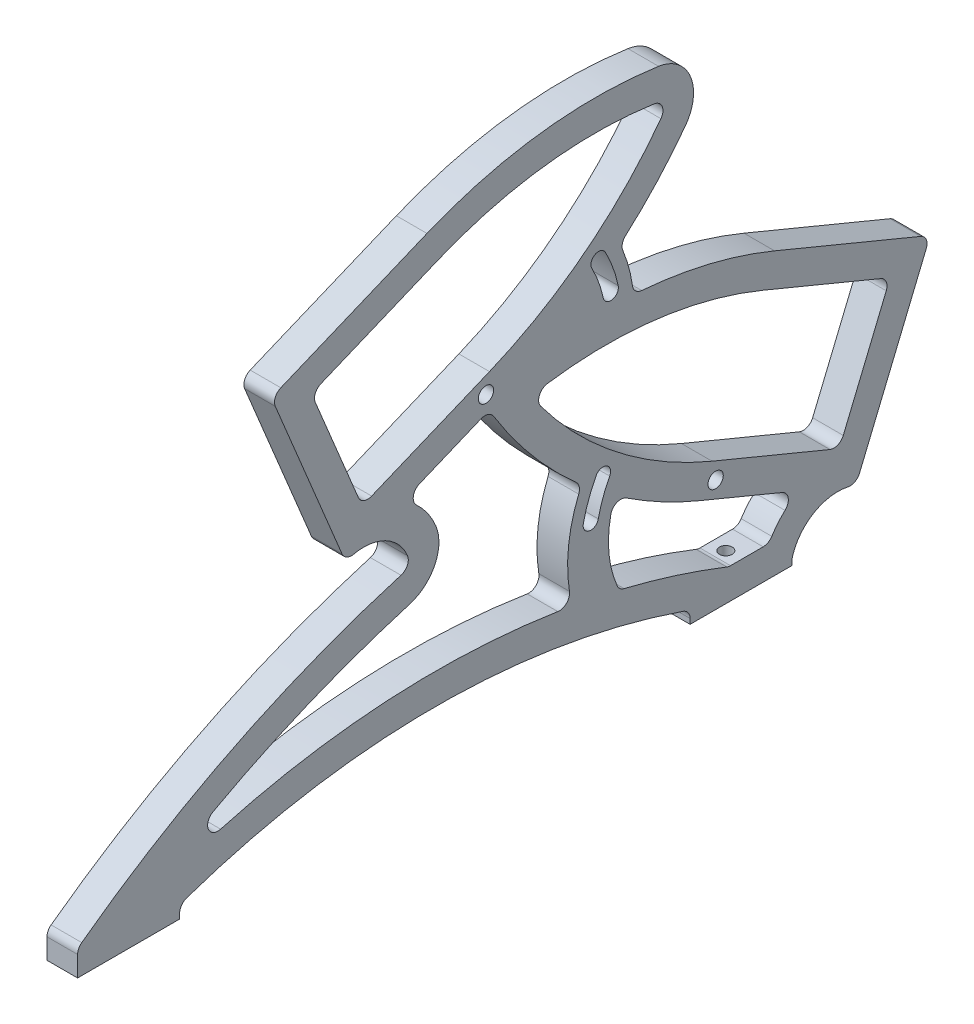
from build123d import *

# Parameters (mm, degrees)
SKETCH1_R                   = 1.5
BOSS_EXTRUDE1_DEPTH         = 6
FILLET1_R                   = 2
TAP_DRILL_FOR_M3_TAP1_D     = 2.5
TAP_DRILL_FOR_M3_TAP1_DEPTH = 10
TAP_DRILL_FOR_M3_TAP1_TIP   = 0.751075774


with BuildPart() as part:
    # Sketch1 → Boss-Extrude1 (new body)
    with BuildSketch(Plane(origin=(0, 0, 0), x_dir=(0, 0, -1), z_dir=(1, 0, 0))):
        with BuildLine():
            Line((0, 0), (0, 5))
            ThreePointArc((0, 5), (30.263904534, 23.654794569), (63.35257649, 36.656527771))
            ThreePointArc((63.35257649, 36.656527771), (64.593543685, 37.712278476), (64.63724154, 39.340989509))
            ThreePointArc((64.63724154, 39.340989509), (59.61305605, 44.365174999), (52.507784789, 44.365174999))
            Line((52.507784789, 44.365174999), (37.965814359, 79.472597235))
            Line((37.965814359, 79.472597235), (68.453838932, 92.101150503))
            ThreePointArc((68.453838932, 92.101150503), (90.758303247, 97.999189725), (113.828291361, 97.771937753))
            ThreePointArc((113.828291361, 97.771937753), (120.071041294, 92.916243967), (119.090244487, 85.068459153))
            ThreePointArc((119.090244487, 85.068459153), (113.049914098, 77.838922298), (106.256946475, 71.311489017))
            ThreePointArc((106.256946475, 71.311489017), (108.007602478, 66.521582509), (108.89212085, 61.499070385))
            ThreePointArc((108.89212085, 61.499070385), (122.984208709, 59.44582567), (136.546161068, 55.101150503))
            Line((136.546161068, 55.101150503), (167.034185641, 42.472597235))
            Line((167.034185641, 42.472597235), (152.492215211, 7.365174999))
            ThreePointArc((152.492215211, 7.365174999), (145.029217261, 7.208101321), (140.094434117, 1.607304426))
            ThreePointArc((140.094434117, 1.607304426), (140.023749539, 1.307301346), (140, 1))
            Line((140, 1), (140, 0))
            Line((140, 0), (120, 0))
            Line((120, 0), (120, 1))
            ThreePointArc((120, 1), (119.627466942, 2.162476387), (118.648648649, 2.891891892))
            ThreePointArc((118.648648649, 2.891891892), (70, 11), (21.351351351, 2.891891892))
            ThreePointArc((21.351351351, 2.891891892), (20.372533058, 2.162476387), (20, 1))
            Line((20, 1), (20, 0))
            Line((20, 0), (0, 0))
        make_face()
        with Locations((80, 59)):
            Circle(SKETCH1_R, mode=Mode.SUBTRACT)
        with Locations((125, 22)):
            Circle(SKETCH1_R, mode=Mode.SUBTRACT)
        with BuildLine():
            Line((63.72452745, 49.011301935), (80.634345003, 56.015577702))
            ThreePointArc((80.634345003, 56.015577702), (88.793282839, 44.416446703), (98.743053525, 34.311489017))
            ThreePointArc((98.743053525, 34.311489017), (96.120508219, 24.64101391), (96.9455023, 14.655263189))
            ThreePointArc((96.9455023, 14.655263189), (53.225179751, 16.095471906), (10.823862094, 5.340516497))
            ThreePointArc((10.823862094, 5.340516497), (36.939787477, 20.226495708), (65.041858534, 30.899243153))
            ThreePointArc((65.041858534, 30.899243153), (70.005727314, 35.122245973), (70.180518735, 41.637090103))
            ThreePointArc((70.180518735, 41.637090103), (67.559666076, 45.855738901), (63.72452745, 49.011301935))
        make_face(mode=Mode.SUBTRACT)
        with BuildLine():
            Line((80.699708768, 62.537005462), (55.75496139, 52.204552788))
            Line((55.75496139, 52.204552788), (45.805192149, 76.225420634))
            Line((45.805192149, 76.225420634), (70.749939526, 86.557873308))
            ThreePointArc((70.749939526, 86.557873308), (91.502380524, 92.045506075), (112.967077451, 91.834066872))
            ThreePointArc((112.967077451, 91.834066872), (114.527764673, 90.620143611), (114.282565525, 88.658197723))
            ThreePointArc((114.282565525, 88.658197723), (99.254242865, 73.330854875), (80.699708768, 62.537005462))
        make_face(mode=Mode.SUBTRACT)
        with BuildLine():
            Line((124.300291232, 25.537005462), (149.24503861, 15.204552788))
            Line((149.24503861, 15.204552788), (159.194807851, 39.225420634))
            Line((159.194807851, 39.225420634), (134.250060474, 49.557873308))
            ThreePointArc((134.250060474, 49.557873308), (113.497619632, 55.045506055), (92.032922859, 54.834066917))
            ThreePointArc((92.032922859, 54.834066917), (90.472235487, 53.620143544), (90.717434663, 51.658197472))
            ThreePointArc((90.717434663, 51.658197472), (105.745757258, 36.330854779), (124.300291232, 25.537005462))
        make_face(mode=Mode.SUBTRACT)
        with BuildLine():
            Line((122.004190638, 19.993728267), (141.27547255, 12.011301935))
            ThreePointArc((141.27547255, 12.011301935), (137.950950961, 9.410732752), (135.464526627, 6))
            Line((135.464526627, 6), (127.541289523, 6))
            ThreePointArc((127.541289523, 6), (116.964502802, 9.762681734), (106.144506127, 12.754982379))
            ThreePointArc((106.144506127, 12.754982379), (104.029107455, 20.894710056), (105.277139326, 29.211710396))
            ThreePointArc((105.277139326, 29.211710396), (113.384661496, 24.138172602), (122.004190638, 19.993728267))
        make_face(mode=Mode.SUBTRACT)
        with BuildLine():
            ThreePointArc((105.920911419, 64.509659807), (104.901854451, 68.063533798), (103.398111211, 71.440996414))
            ThreePointArc((103.398111211, 71.440996414), (101.369482477, 72.061210459), (100.749268432, 70.032581725))
            ThreePointArc((100.749268432, 70.032581725), (102.082776588, 67.037473368), (102.986468617, 63.885924734))
            ThreePointArc((102.986468617, 63.885924734), (104.765557555, 62.730570869), (105.920911419, 64.509659807))
        make_face(mode=Mode.SUBTRACT)
        with BuildLine():
            ThreePointArc((101.601888789, 34.440996414), (100.098145549, 31.063533798), (99.079088581, 27.509659807))
            ThreePointArc((99.079088581, 27.509659807), (100.234442445, 25.730570869), (102.013531383, 26.885924734))
            ThreePointArc((102.013531383, 26.885924734), (102.917223412, 30.037473368), (104.250731568, 33.032581725))
            ThreePointArc((104.250731568, 33.032581725), (103.630517523, 35.061210459), (101.601888789, 34.440996414))
        make_face(mode=Mode.SUBTRACT)
    extrude(amount=BOSS_EXTRUDE1_DEPTH)

    # Fillet1
    fillet1_edges = [part.edges().sort_by_distance(p)[0] for p in [
        (3, 34.311489017, -98.743053525),
        (3, 56.015577702, -80.634345003),
        (3, 49.011301935, -63.72452745),
        (3, 5.340516497, -10.823862094),
        (3, 14.655263189, -96.9455023),
        (3, 76.225420634, -45.805192149),
        (3, 52.204552788, -55.75496139),
        (3, 15.204552788, -149.24503861),
        (3, 39.225420634, -159.194807851),
        (3, 5, 0),
        (3, 44.365174999, -52.507784789),
        (3, 79.472597235, -37.965814359),
        (3, 71.311489017, -106.256946475),
        (3, 61.499070385, -108.89212085),
        (3, 42.472597235, -167.034185641),
        (3, 7.365174999, -152.492215211),
        (3, 29.211710396, -105.277139326),
        (3, 12.754982379, -106.144506127),
        (3, 6, -127.541289523),
        (3, 6, -135.464526627),
        (3, 12.011301935, -141.27547255),
    ]]
    fillet(fillet1_edges, radius=FILLET1_R)

    # Tap Drill for M3 Tap1
    with Locations(Plane(origin=(0, 0, 0), x_dir=(-1, 0, 0), z_dir=(0, -1, 0))):
        with Locations((-3, 10), (-3, 130)):
            Hole(TAP_DRILL_FOR_M3_TAP1_D / 2, depth=TAP_DRILL_FOR_M3_TAP1_DEPTH)
            with Locations((0, 0, -(TAP_DRILL_FOR_M3_TAP1_DEPTH + TAP_DRILL_FOR_M3_TAP1_TIP / 2))):  # 118° drill point
                Cone(0, TAP_DRILL_FOR_M3_TAP1_D / 2, TAP_DRILL_FOR_M3_TAP1_TIP, mode=Mode.SUBTRACT)


solid = part.part
